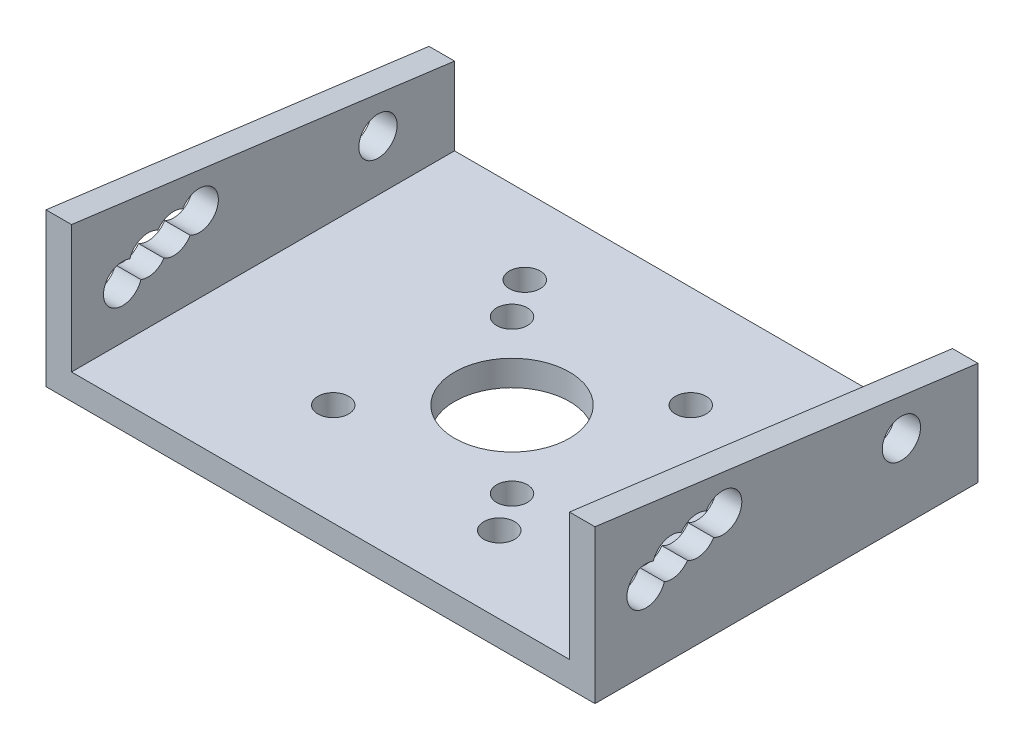
from build123d import *

# Parameters (mm, degrees)
ESBO_O1_W                = 43
ESBO_O1_H                = 30
ESBO_O1_R                = 4.5
ESBO_O1_R_2              = 1.205837633
RESSALTO_EXTRUS_O1_DEPTH = 2
ESBO_O2_R                = 1.5
RESSALTO_EXTRUS_O2_DEPTH = 2


with BuildPart() as part:
    # Esboço1 → Ressalto-extrusão1 (new body)
    with BuildSketch(Plane(origin=(0, 0, 0), x_dir=(1, 0, 0), z_dir=(0, 1, 0))):
        Rectangle(ESBO_O1_W, ESBO_O1_H)
        Circle(ESBO_O1_R, mode=Mode.SUBTRACT)
        with Locations((7, 7)):
            Circle(ESBO_O1_R_2, mode=Mode.SUBTRACT)
        with Locations((-6, 6)):
            Circle(ESBO_O1_R_2, mode=Mode.SUBTRACT)
        with Locations((-8, 9)):
            Circle(ESBO_O1_R_2, mode=Mode.SUBTRACT)
        with Locations((-7, -7)):
            Circle(ESBO_O1_R_2, mode=Mode.SUBTRACT)
        with Locations((6, -6)):
            Circle(ESBO_O1_R_2, mode=Mode.SUBTRACT)
        with Locations((8, -9)):
            Circle(ESBO_O1_R_2, mode=Mode.SUBTRACT)
    extrude(amount=RESSALTO_EXTRUS_O1_DEPTH)

    # Esboço2 → Ressalto-extrusão2 (add)
    with BuildSketch(Plane.ZY.offset(21.5)):
        Polygon((15, 2), (15, 12), (-15, 8.089445099), (-15, 2), align=None)
        with Locations((-9, 6)):
            Circle(ESBO_O2_R, mode=Mode.SUBTRACT)
        with BuildLine():
            ThreePointArc((8.240400933, 8.233448591), (9.539925295, 8.339457279), (10.431505763, 7.388097368))
            ThreePointArc((10.431505763, 7.388097368), (11.835840488, 7.245540316), (12.5, 6))
            ThreePointArc((12.5, 6), (11.226651005, 4.51722243), (9.568494237, 5.551902632))
            ThreePointArc((9.568494237, 5.551902632), (8.567535869, 5.503694052), (7.759599067, 6.096551409))
            ThreePointArc((7.759599067, 6.096551409), (6.624037685, 5.937880054), (5.708151293, 6.62768319))
            ThreePointArc((5.708151293, 6.62768319), (3.55555397, 8.354444888), (6.291848707, 8.71231681))
            ThreePointArc((6.291848707, 8.71231681), (7.357982, 8.84665675), (8.240400933, 8.233448591))
        make_face(mode=Mode.SUBTRACT)
    ressalto_extrus_o2 = extrude(amount=-RESSALTO_EXTRUS_O2_DEPTH)

    # Espelhar1: Ressalto-extrusão2 across plane
    add(ressalto_extrus_o2.mirror(Plane(origin=(0, 0, 0), x_dir=(0, 0, 1), z_dir=(1, 0, 0))))


solid = part.part
